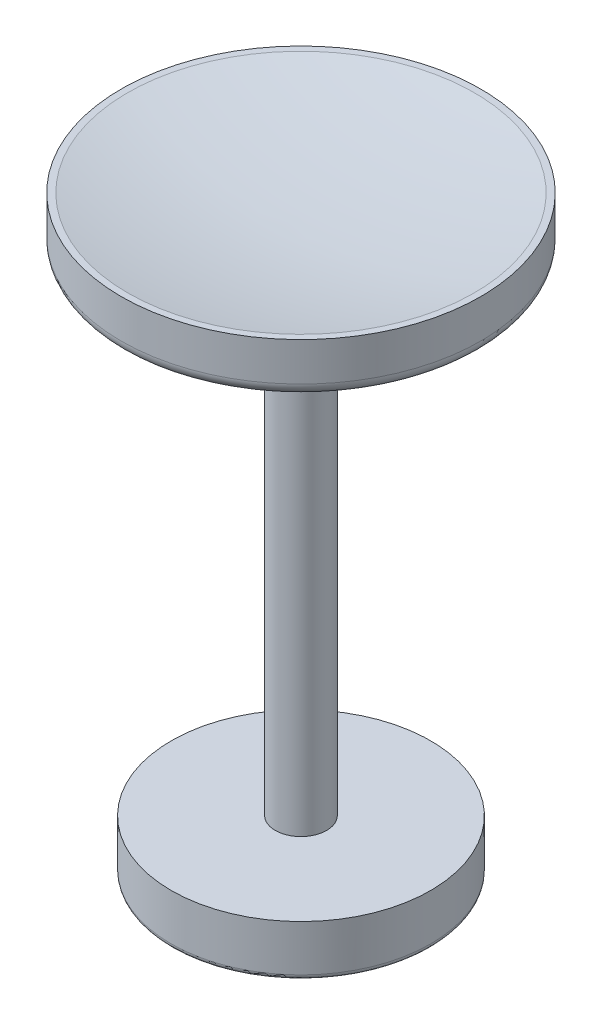
from build123d import *

# Parameters (mm, degrees)
SKETCH1_R           = 17.78
BOSS_EXTRUDE1_DEPTH = 2.54
FILLET1_R           = 0.508
FILLET2_R           = 1.27


with BuildPart() as part:
    # Sketch1 → Boss-Extrude1 (new body)
    with BuildSketch(Plane(origin=(0, 0, 0), x_dir=(1, 0, 0), z_dir=(0, 1, 0))):
        Circle(SKETCH1_R)
    extrude(amount=BOSS_EXTRUDE1_DEPTH)

    # Sketch2 → Revolve1 (revolve)
    with BuildSketch(Plane(origin=(0, 0, 0), x_dir=(0, 0, -1), z_dir=(1, 0, 0))):
        with BuildLine():
            Line((-17.78, 2.54), (-17.78, 5.08))
            Line((-17.78, 5.08), (-17.145, 5.08))
            ThreePointArc((-17.145, 5.08), (-8.625254344, 3.652710903), (0, 3.175))
            Line((0, 3.175), (0, 2.54))
            Line((0, 2.54), (-17.78, 2.54))
        make_face()
        Polygon((0, 0), (0, -53.34), (-12.827, -53.34), (-12.827, -48.26), (-2.54, -48.26), (-2.54, 0), align=None)
    revolve(axis=Axis((0, 0, 0), (0, -1, 0)))

    # Fillet1
    fillet1_edges = [part.edges().sort_by_distance(p)[0] for p in [
        (0, -53.34, -12.827),
    ]]
    fillet(fillet1_edges, radius=FILLET1_R)

    # Fillet2
    fillet2_edges = [part.edges().sort_by_distance(p)[0] for p in [
        (-17.78, 0, 0),
    ]]
    fillet(fillet2_edges, radius=FILLET2_R)


solid = part.part
